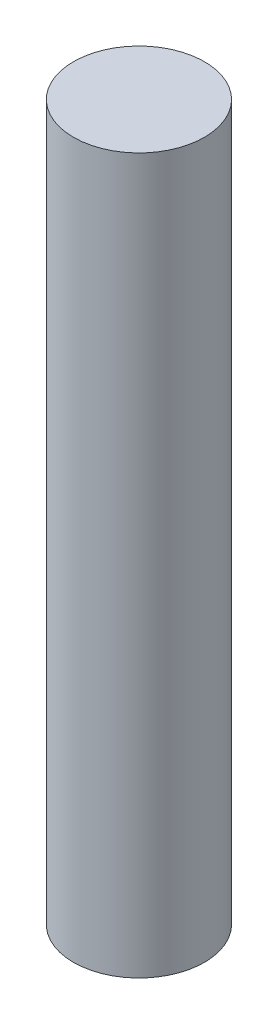
from build123d import *

# Parameters (mm, degrees)
SKETCH1_R           = 5.5
BOSS_EXTRUDE1_DEPTH = 60


with BuildPart() as part:
    # Sketch1 → Boss-Extrude1 (new body)
    with BuildSketch(Plane(origin=(0, 0, 0), x_dir=(1, 0, 0), z_dir=(0, 1, 0))):
        Circle(SKETCH1_R)
    extrude(amount=BOSS_EXTRUDE1_DEPTH)


solid = part.part
